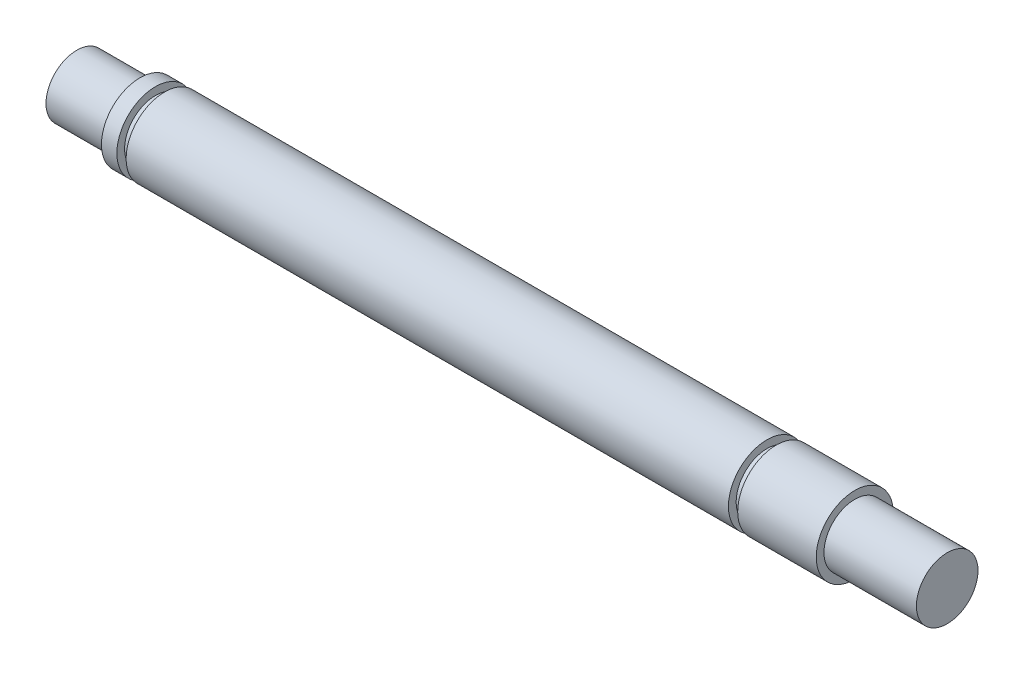
from build123d import *

# Parameters (mm, degrees)
M4_CLEARANCE_HOLE5_D     = 4.5
M4_CLEARANCE_HOLE5_DEPTH = 5.1
M4_CLEARANCE_HOLE5_TIP   = 1.351936393
SKETCH17_R               = 4
BOSS_EXTRUDE1_DEPTH      = 12


with BuildPart() as part:
    # Sketch1 → Revolve1 (revolve)
    with BuildSketch(Plane.XY):
        Polygon((-39.2, -5), (39, -5), (39, -4), (40.2, -4), (40.2, -5), (50.4, -5), (50.4, 0), (-50.6, 0), (-50.6, -4), (-42.4, -4), (-42.4, -5), (-40.4, -5), (-40.4, -4), (-39.2, -4), align=None)
    revolve(axis=Axis((0, 0, 0), (1, 0, 0)))

    # M4 Clearance Hole5
    with Locations(Plane(origin=(44.4, -5, 0), x_dir=(0, 0, -1), z_dir=(0, -1, 0))):
        with Locations((0, 0)):
            Hole(M4_CLEARANCE_HOLE5_D / 2, depth=M4_CLEARANCE_HOLE5_DEPTH)
            with Locations((0, 0, -(M4_CLEARANCE_HOLE5_DEPTH + M4_CLEARANCE_HOLE5_TIP / 2))):  # 118° drill point
                Cone(0, M4_CLEARANCE_HOLE5_D / 2, M4_CLEARANCE_HOLE5_TIP, mode=Mode.SUBTRACT)

    # Sketch17 → Boss-Extrude1 (add)
    with BuildSketch(Plane(origin=(50.4, 0, 0), x_dir=(0, 0, -1), z_dir=(1, 0, 0))):
        Circle(SKETCH17_R)
    extrude(amount=BOSS_EXTRUDE1_DEPTH)


solid = part.part
